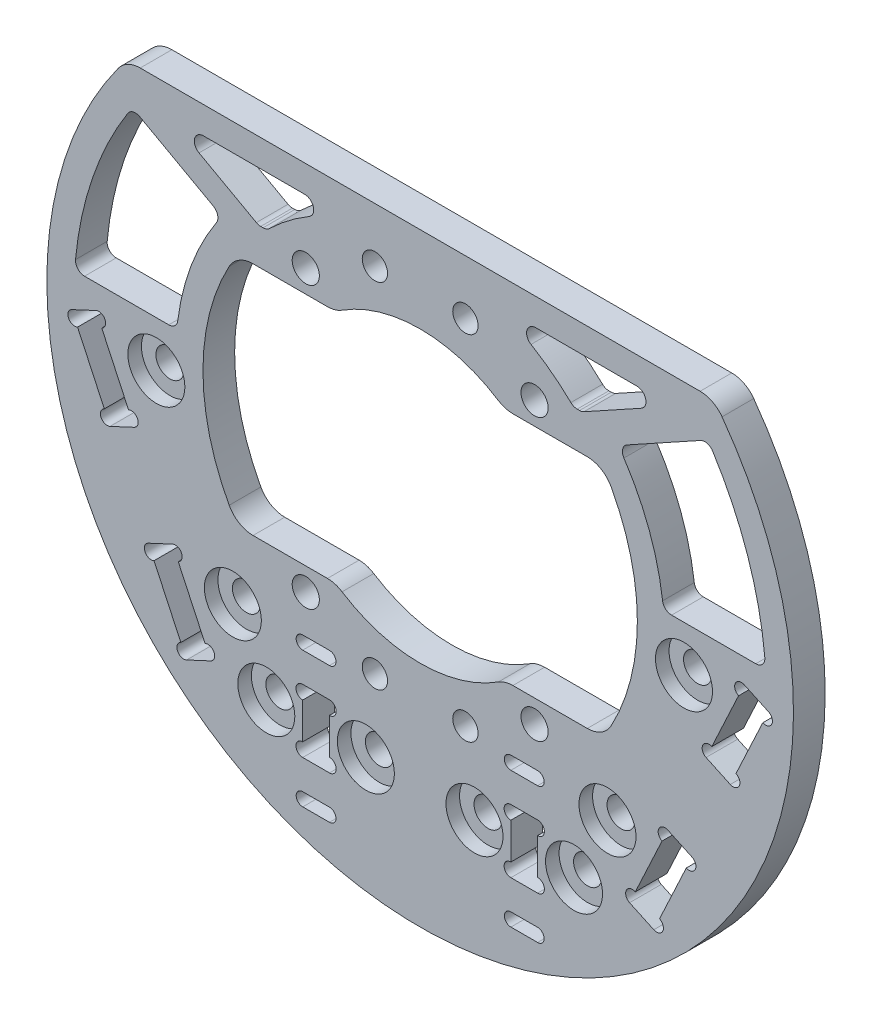
from build123d import *

# Parameters (mm, degrees)
SKETCH_1_R          = 1.5
EXTRUDE_1_DEPTH     = 1.75
FILLET_2_R          = 3
FILLET_3_R          = 3
SKETCH_2_R          = 1.55
CUT_EXTRUDE_1_DEPTH = 4.5
SKETCH_3_R          = 3.15
CUT_EXTRUDE_2_DEPTH = 1.5
SKETCH_4_R          = 0.75
CUT_EXTRUDE_3_DEPTH = 4.5
SKETCH_5_R          = 1.4
CUT_EXTRUDE_4_DEPTH = 4.5
CUT_EXTRUDE_5_DEPTH = 4.5
EXTRUDE_2_DEPTH     = 3.5
FILLET_5_R          = 1
SKETCH_8_R          = 1.55
SKETCH_8_W          = 2.95
SKETCH_8_H          = 7
SKETCH_8_H_2        = 1.45
CUT_EXTRUDE_6_DEPTH = 4.5
SKETCH_9_R          = 0.75
SKETCH_9_R_2        = 0.725
CUT_EXTRUDE_7_DEPTH = 4.5
SKETCH_12_R         = 3.15
CUT_EXTRUDE_8_DEPTH = 1.5


with BuildPart() as part:
    # 草图1 → 凸台-拉伸1 (new body, symmetric)
    with BuildSketch(Plane.XY):
        with BuildLine():
            Line((-32.423949482, 25.5), (32.423949482, 25.5))
            ThreePointArc((32.423949482, 25.5), (0, -41.25), (-32.423949482, 25.5))
        make_face()
        with Locations((-12.63922466, 15.5)):
            Circle(SKETCH_1_R, mode=Mode.SUBTRACT)
        with Locations((-12.63922466, -15.5)):
            Circle(SKETCH_1_R, mode=Mode.SUBTRACT)
        with Locations((12.63922466, -15.5)):
            Circle(SKETCH_1_R, mode=Mode.SUBTRACT)
        with Locations((12.63922466, 15.5)):
            Circle(SKETCH_1_R, mode=Mode.SUBTRACT)
        with BuildLine():
            Line((-20.174241002, 13), (-9.327379053, 13))
            ThreePointArc((-9.327379053, 13), (0, 16), (9.327379053, 13))
            Line((9.327379053, 13), (20.174241002, 13))
            ThreePointArc((20.174241002, 13), (24, 0), (20.174241002, -13))
            Line((20.174241002, -13), (9.327379053, -13))
            ThreePointArc((9.327379053, -13), (0, -16), (-9.327379053, -13))
            Line((-9.327379053, -13), (-20.174241002, -13))
            ThreePointArc((-20.174241002, -13), (-24, 0), (-20.174241002, 13))
        make_face(mode=Mode.SUBTRACT)
    extrude(amount=EXTRUDE_1_DEPTH, both=True)

    # 圆角2
    fillet_2_edges = [part.edges().sort_by_distance(p)[0] for p in [
        (-9.327379053, -13, 0),
        (9.327379053, -13, 0),
        (20.174241002, -13, 0),
        (20.174241002, 13, 0),
        (9.327379053, 13, 0),
        (-9.327379053, 13, 0),
        (-20.174241002, 13, 0),
        (-20.174241002, -13, 0),
    ]]
    fillet(fillet_2_edges, radius=FILLET_2_R)

    # 圆角3
    fillet_3_edges = [part.edges().sort_by_distance(p)[0] for p in [
        (-32.423949482, 25.5, 0),
        (32.423949482, 25.5, 0),
    ]]
    fillet(fillet_3_edges, radius=FILLET_3_R)

    # 草图2 → 切除-拉伸1 (cut, through all)
    with BuildSketch(Plane(origin=(0, 0, -1.75), x_dir=(-1, 0, 0), z_dir=(0, 0, -1))):
        with Locations((-29.149646761, -2.558924328)):
            Circle(SKETCH_2_R)
        with Locations((-20.697281526, -20.685080068)):
            Circle(SKETCH_2_R)
        with Locations((20.697281526, -20.685080068)):
            Circle(SKETCH_2_R)
        with Locations((29.149646761, -2.558924328)):
            Circle(SKETCH_2_R)
        Polygon((35.816934699, -0.151042158), (38.490542671, -1.39776603), (34.264360054, -10.4608439), (31.590752082, -9.214120028), align=None)
        Polygon((-31.590752082, -9.214120028), (-34.264360054, -10.4608439), (-38.490542671, -1.39776603), (-35.816934699, -0.151042158), align=None)
        Polygon((-23.138386847, -27.340275769), (-25.811994819, -28.586999641), (-30.038177436, -19.52392177), (-27.364569465, -18.277197898), align=None)
        Polygon((27.364569465, -18.277197898), (23.138386847, -27.340275769), (25.811994819, -28.586999641), (30.038177436, -19.52392177), align=None)
    extrude(amount=-CUT_EXTRUDE_1_DEPTH, mode=Mode.SUBTRACT)

    # 草图3 → 切除-拉伸2 (cut)
    with BuildSketch(Plane.XY.offset(1.75)):
        with Locations((-29.149646761, -2.558924328)):
            Circle(SKETCH_3_R)
        with Locations((-20.697281526, -20.685080068)):
            Circle(SKETCH_3_R)
        with Locations((29.149646761, -2.558924328)):
            Circle(SKETCH_3_R)
        with Locations((20.697281526, -20.685080068)):
            Circle(SKETCH_3_R)
    extrude(amount=-CUT_EXTRUDE_2_DEPTH, mode=Mode.SUBTRACT)

    # 草图4 → 切除-拉伸3 (cut, through all)
    with BuildSketch(Plane(origin=(0, 0, -1.75), x_dir=(-1, 0, 0), z_dir=(0, 0, -1))):
        with Locations((-35.499971003, -0.830772998)):
            Circle(SKETCH_4_R)
        with Locations((-31.907715778, -8.534389188)):
            Circle(SKETCH_4_R)
        with Locations((-34.58132375, -9.78111306)):
            Circle(SKETCH_4_R)
        with Locations((-38.173578975, -2.07749687)):
            Circle(SKETCH_4_R)
        with Locations((35.499971003, -0.830772998)):
            Circle(SKETCH_4_R)
        with Locations((38.173578975, -2.07749687)):
            Circle(SKETCH_4_R)
        with Locations((31.907715778, -8.534389188)):
            Circle(SKETCH_4_R)
        with Locations((34.58132375, -9.78111306)):
            Circle(SKETCH_4_R)
        with Locations((-29.72121374, -20.203652611)):
            Circle(SKETCH_4_R)
        with Locations((-27.047605768, -18.956928739)):
            Circle(SKETCH_4_R)
        with Locations((-26.128958515, -27.907268801)):
            Circle(SKETCH_4_R)
        with Locations((-23.455350544, -26.660544928)):
            Circle(SKETCH_4_R)
        with Locations((23.455350544, -26.660544928)):
            Circle(SKETCH_4_R)
        with Locations((26.128958515, -27.907268801)):
            Circle(SKETCH_4_R)
        with Locations((27.047605768, -18.956928739)):
            Circle(SKETCH_4_R)
        with Locations((29.72121374, -20.203652611)):
            Circle(SKETCH_4_R)
    extrude(amount=-CUT_EXTRUDE_3_DEPTH, mode=Mode.SUBTRACT)

    # 草图5 → 切除-拉伸4 (cut, through all)
    with BuildSketch(Plane(origin=(0, 0, -1.75), x_dir=(-1, 0, 0), z_dir=(0, 0, -1))):
        with Locations((-5, 19.5)):
            Circle(SKETCH_5_R)
        with Locations((5, 19.5)):
            Circle(SKETCH_5_R)
        with Locations((-5, -19.5)):
            Circle(SKETCH_5_R)
        with Locations((5, -19.5)):
            Circle(SKETCH_5_R)
    extrude(amount=-CUT_EXTRUDE_4_DEPTH, mode=Mode.SUBTRACT)

    # 草图6 → 切除-拉伸5 (cut, through all)
    with BuildSketch(Plane(origin=(0, 0, -1.75), x_dir=(-1, 0, 0), z_dir=(0, 0, -1))):
        with BuildLine():
            Line((-20.976176963, 17), (-16.941074346, 17))
            ThreePointArc((-16.941074346, 17), (-12.941906062, 20.21155777), (-8.351646544, 22.5))
            Line((-8.351646544, 22.5), (-30.932385941, 22.5))
            ThreePointArc((-30.932385941, 22.5), (-35.96836389, 13.013043421), (-38.168213215, 2.5))
            Line((-38.168213215, 2.5), (-26.884010118, 2.5))
            ThreePointArc((-26.884010118, 2.5), (-25.004237178, 10.187645613), (-20.976176963, 17))
        make_face()
        with BuildLine():
            Line((38.168213215, 2.5), (26.884010118, 2.5))
            ThreePointArc((26.884010118, 2.5), (25.004237178, 10.187645613), (20.976176963, 17))
            Line((20.976176963, 17), (16.941074346, 17))
            ThreePointArc((16.941074346, 17), (12.941906062, 20.21155777), (8.351646544, 22.5))
            Line((8.351646544, 22.5), (30.932385941, 22.5))
            ThreePointArc((30.932385941, 22.5), (35.96836389, 13.013043421), (38.168213215, 2.5))
        make_face()
    extrude(amount=-CUT_EXTRUDE_5_DEPTH, mode=Mode.SUBTRACT)

    # 草图7 → 凸台-拉伸2 (add)
    with BuildSketch(Plane(origin=(0, 0, -1.75), x_dir=(-1, 0, 0), z_dir=(0, 0, -1))):
        with BuildLine():
            Line((-31.795356042, 21.263062671), (-21.897631543, 15.795370614))
            ThreePointArc((-21.897631543, 15.795370614), (-21.44536423, 16.404156579), (-20.976176963, 17))
            Line((-20.976176963, 17), (-17.8740784, 17))
            Line((-17.8740784, 17), (-27.830287378, 22.5))
            Line((-27.830287378, 22.5), (-30.932385941, 22.5))
            ThreePointArc((-30.932385941, 22.5), (-31.369968235, 21.88578518), (-31.795356042, 21.263062671))
        make_face()
        with BuildLine():
            Line((27.830287378, 22.5), (30.932385941, 22.5))
            ThreePointArc((30.932385941, 22.5), (31.369968235, 21.88578518), (31.795356042, 21.263062671))
            Line((31.795356042, 21.263062671), (21.897631543, 15.795370614))
            ThreePointArc((21.897631543, 15.795370614), (21.44536423, 16.404156579), (20.976176963, 17))
            Line((20.976176963, 17), (17.8740784, 17))
            Line((17.8740784, 17), (27.830287378, 22.5))
        make_face()
    extrude(amount=-EXTRUDE_2_DEPTH)

    # 圆角5
    fillet_5_edges = [part.edges().sort_by_distance(p)[0] for p in [
        (8.351646544, 22.5, 0),
        (16.941074346, 17, 0),
        (26.884010118, 2.5, 0),
        (38.168213215, 2.5, 0),
        (-26.884010118, 2.5, 0),
        (-16.941074346, 17, 0),
        (-8.351646544, 22.5, 0),
        (-38.168213215, 2.5, 0),
        (31.795356042, 21.263062671, 0),
        (27.830287378, 22.5, 0),
        (17.8740784, 17, 0),
        (21.897631543, 15.795370614, 0),
        (-31.795356042, 21.263062671, 0),
        (-21.897631543, 15.795370614, 0),
        (-17.8740784, 17, 0),
        (-27.830287378, 22.5, 0),
    ]]
    fillet(fillet_5_edges, radius=FILLET_5_R)

    # 草图8 → 切除-拉伸6 (cut, through all)
    with BuildSketch(Plane(origin=(0, 0, -1.75), x_dir=(-1, 0, 0), z_dir=(0, 0, -1))):
        with Locations((-17, -28)):
            Circle(SKETCH_8_R)
        with Locations((-6, -28)):
            Circle(SKETCH_8_R)
        with Locations((6, -28)):
            Circle(SKETCH_8_R)
        with Locations((17, -28)):
            Circle(SKETCH_8_R)
        with Locations((11.5, -28)):
            Rectangle(SKETCH_8_W, SKETCH_8_H)
        with Locations((-11.5, -28)):
            Rectangle(SKETCH_8_W, SKETCH_8_H)
        with Locations((-11.5, -20.5)):
            Rectangle(SKETCH_8_W, SKETCH_8_H_2)
        with Locations((-11.5, -35.5)):
            Rectangle(SKETCH_8_W, SKETCH_8_H_2)
        with Locations((11.5, -35.5)):
            Rectangle(SKETCH_8_W, SKETCH_8_H_2)
        with Locations((11.5, -20.5)):
            Rectangle(SKETCH_8_W, SKETCH_8_H_2)
    extrude(amount=-CUT_EXTRUDE_6_DEPTH, mode=Mode.SUBTRACT)

    # 草图9 → 切除-拉伸7 (cut, through all)
    with BuildSketch(Plane(origin=(0, 0, -1.75), x_dir=(-1, 0, 0), z_dir=(0, 0, -1))):
        with Locations((-12.975, -25.25)):
            Circle(SKETCH_9_R)
        with Locations((-10.025, -25.25)):
            Circle(SKETCH_9_R)
        with Locations((-12.975, -30.75)):
            Circle(SKETCH_9_R)
        with Locations((-10.025, -30.75)):
            Circle(SKETCH_9_R)
        with Locations((10.025, -25.25)):
            Circle(SKETCH_9_R)
        with Locations((12.975, -25.25)):
            Circle(SKETCH_9_R)
        with Locations((10.025, -30.75)):
            Circle(SKETCH_9_R)
        with Locations((12.975, -30.75)):
            Circle(SKETCH_9_R)
        with Locations((-10.025, -20.5)):
            Circle(SKETCH_9_R_2)
        with Locations((-12.975, -20.5)):
            Circle(SKETCH_9_R_2)
        with Locations((-10.025, -35.5)):
            Circle(SKETCH_9_R_2)
        with Locations((-12.975, -35.5)):
            Circle(SKETCH_9_R_2)
        with Locations((12.975, -20.5)):
            Circle(SKETCH_9_R_2)
        with Locations((10.025, -20.5)):
            Circle(SKETCH_9_R_2)
        with Locations((12.975, -35.5)):
            Circle(SKETCH_9_R_2)
        with Locations((10.025, -35.5)):
            Circle(SKETCH_9_R_2)
    extrude(amount=-CUT_EXTRUDE_7_DEPTH, mode=Mode.SUBTRACT)

    # 草图12 → 切除-拉伸8 (cut)
    with BuildSketch(Plane.XY.offset(1.75)):
        with Locations((-17, -28)):
            Circle(SKETCH_12_R)
        with Locations((17, -28)):
            Circle(SKETCH_12_R)
        with Locations((-6, -28)):
            Circle(SKETCH_12_R)
        with Locations((6, -28)):
            Circle(SKETCH_12_R)
    extrude(amount=-CUT_EXTRUDE_8_DEPTH, mode=Mode.SUBTRACT)


solid = part.part
